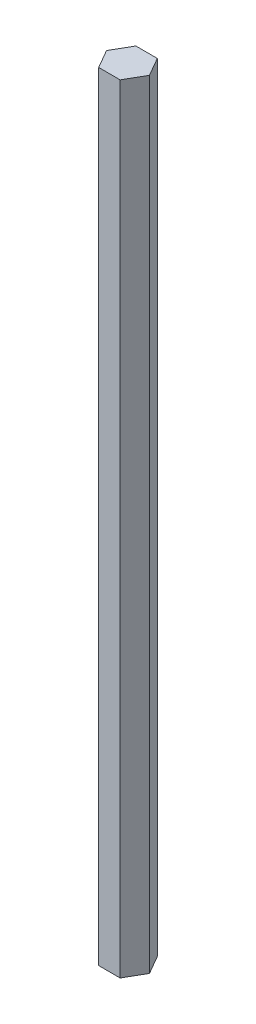
from build123d import *

# Parameters (mm, degrees)
BOSS_EXTRUDE1_DEPTH = 290


with BuildPart() as part:
    # Sketch1 → Boss-Extrude1 (new body)
    with BuildSketch(Plane(origin=(0, 0, 0), x_dir=(1, 0, 0), z_dir=(0, 1, 0))):
        Polygon((7.977059052, 1.579344013), (3.977059052, 8.507547244), (-4.022940948, 8.507547244), (-8.022940948, 1.579344013), (-4.022940948, -5.348859217), (3.977059052, -5.348859217), align=None)
    extrude(amount=BOSS_EXTRUDE1_DEPTH)


solid = part.part
